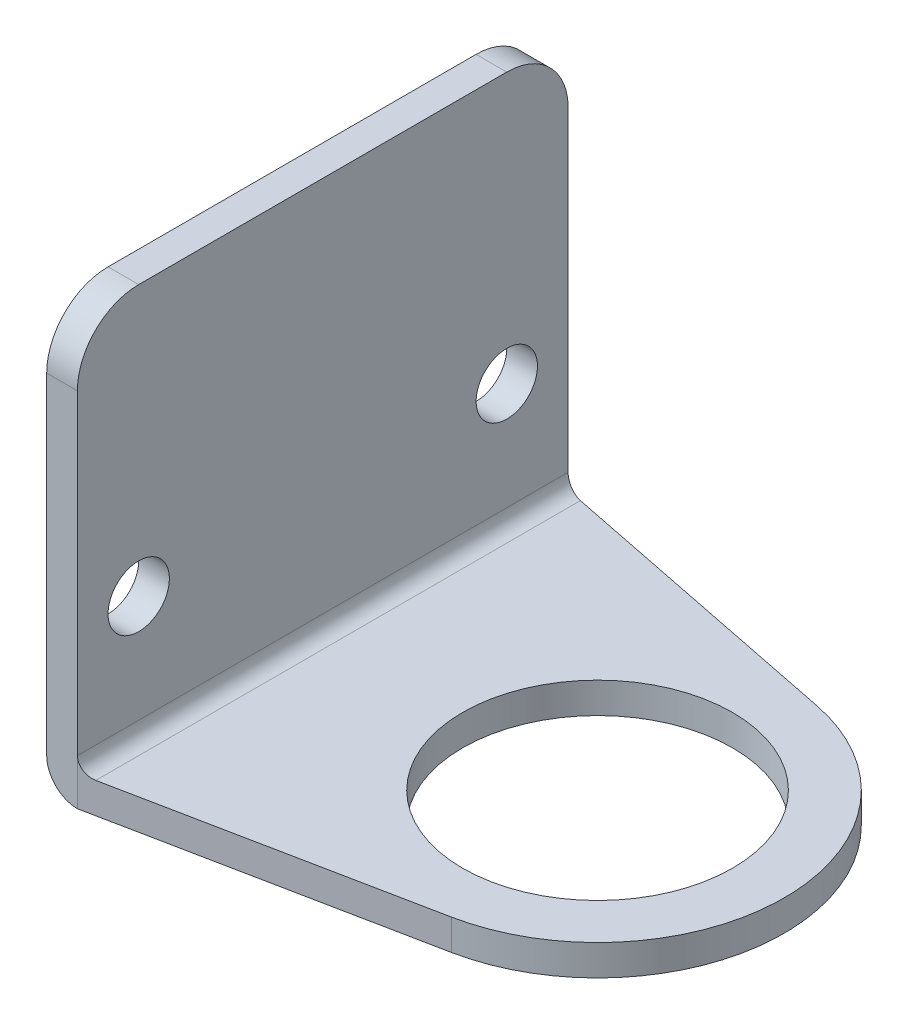
from build123d import *

# Parameters (mm, degrees)
SKETCH1_R           = 13.97
BOSS_EXTRUDE1_DEPTH = 3.175
SKETCH2_W           = 3.175
SKETCH2_H           = 50.8
BOSS_EXTRUDE2_DEPTH = 40.64
FILLET1_R           = 1.5875
FILLET2_R           = 3.175
SKETCH6_R           = 3.175
CUT_EXTRUDE2_DEPTH  = 51.927
FILLET3_R           = 6.35


with BuildPart() as part:
    # Sketch1 → Boss-Extrude1 (new body)
    with BuildSketch(Plane(origin=(0, 0, 0), x_dir=(1, 0, 0), z_dir=(0, 1, 0))):
        with BuildLine():
            ThreePointArc((3.799431403, -18.926403172), (19.304, 0), (3.799431403, 18.926403172))
            Line((3.799431403, 18.926403172), (-28.448, 25.4))
            Line((-28.448, 25.4), (-31.623, 25.4))
            Line((-31.623, 25.4), (-31.623, -25.4))
            Line((-31.623, -25.4), (-28.448, -25.4))
            Line((-28.448, -25.4), (3.799431403, -18.926403172))
        make_face()
        Circle(SKETCH1_R, mode=Mode.SUBTRACT)
    extrude(amount=BOSS_EXTRUDE1_DEPTH)

    # Sketch2 → Boss-Extrude2 (add)
    with BuildSketch(Plane(origin=(0, 3.175, 0), x_dir=(1, 0, 0), z_dir=(0, 1, 0))):
        with Locations((-30.0355, 0)):
            Rectangle(SKETCH2_W, SKETCH2_H)
    extrude(amount=BOSS_EXTRUDE2_DEPTH)

    # Fillet1
    fillet1_edges = [part.edges().sort_by_distance(p)[0] for p in [
        (-28.448, 3.175, 0),
    ]]
    fillet(fillet1_edges, radius=FILLET1_R)

    # Fillet2
    fillet2_edges = [part.edges().sort_by_distance(p)[0] for p in [
        (-31.623, 0, 0),
    ]]
    fillet(fillet2_edges, radius=FILLET2_R)

    # Sketch6 → Cut-Extrude2 (cut, through all)
    with BuildSketch(Plane.ZY.offset(31.623)):
        with Locations((-19.05, 15.875)):
            Circle(SKETCH6_R)
        with Locations((19.05, 15.875)):
            Circle(SKETCH6_R)
    extrude(amount=-CUT_EXTRUDE2_DEPTH, mode=Mode.SUBTRACT)

    # Fillet3
    fillet3_edges = [part.edges().sort_by_distance(p)[0] for p in [
        (-30.0355, 43.815, -25.4),
        (-30.0355, 43.815, 25.4),
    ]]
    fillet(fillet3_edges, radius=FILLET3_R)


solid = part.part
